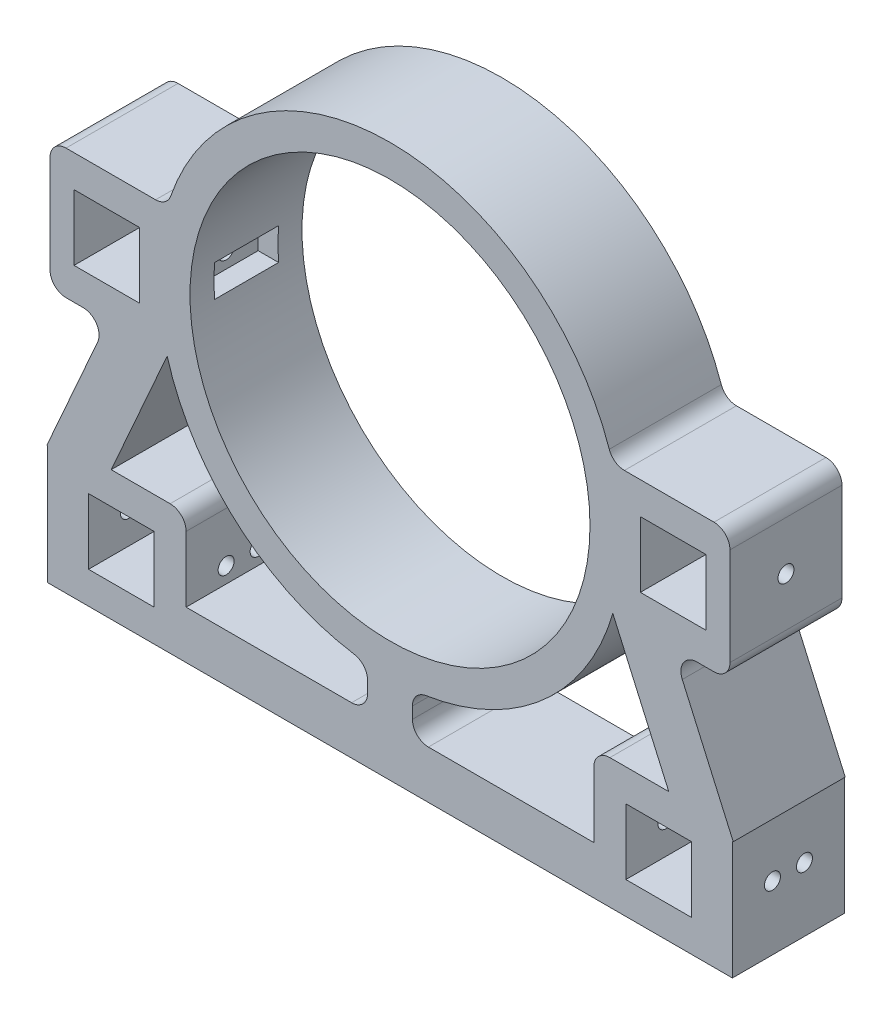
from build123d import *

# Parameters (mm, degrees)
SKETCH1_W                = 20.5
SKETCH1_H                = 20.5
SKETCH1_R                = 62.5
BOSS_EXTRUDE1_DEPTH      = 35
FILLET2_R                = 5
SKETCH2_W                = 20
SKETCH2_H                = 10
CUT_EXTRUDE2_DEPTH       = 7
SKETCH3_W                = 20
SKETCH3_H                = 10
CUT_EXTRUDE3_DEPTH       = 7
SKETCH4_W                = 35
SKETCH4_H                = 37
CUT_EXTRUDE4_DEPTH       = 10
SKETCH5_W                = 35
SKETCH5_H                = 37
CUT_EXTRUDE5_DEPTH       = 10
SKETCH6_W                = 35
SKETCH6_H                = 40.5
CUT_EXTRUDE8_DEPTH       = 2.5
SKETCH7_W                = 35
SKETCH7_H                = 40.5
CUT_EXTRUDE9_DEPTH       = 2.5
FILLET3_R                = 5
SKETCH8_R                = 2.5
CUT_EXTRUDE10_DEPTH      = 194
CUT_EXTRUDE10_DEPTH_BACK = 48
SKETCH9_R                = 2.5
CUT_EXTRUDE11_DEPTH      = 48
CUT_EXTRUDE11_DEPTH_BACK = 48
SKETCH10_R               = 2.5
CUT_EXTRUDE12_DEPTH      = 48
CUT_EXTRUDE12_DEPTH_BACK = 48


with BuildPart() as part:
    # Sketch1 → Boss-Extrude1 (new body)
    with BuildSketch(Plane.XY):
        with BuildLine():
            Line((117, -100.161277705), (117, -85.161277705))
            Line((117, -85.161277705), (88.226517383, -20.181680312))
            Line((88.226517383, -20.181680312), (108.734784021, -20.181680312))
            Line((108.734784021, -20.181680312), (108.734784021, 20.318319688))
            Line((108.734784021, 20.318319688), (69.594654141, 20.318319688))
            ThreePointArc((69.594654141, 20.318319688), (0, 72.5), (-69.594654141, 20.318319688))
            Line((-69.594654141, 20.318319688), (-108.734784021, 20.318319688))
            Line((-108.734784021, 20.318319688), (-108.734784021, -20.181680312))
            Line((-108.734784021, -20.181680312), (-88.226517383, -20.181680312))
            Line((-88.226517383, -20.181680312), (-117, -85.161277705))
            Line((-117, -85.161277705), (-117, -100.161277705))
            Line((-117, -100.161277705), (117, -100.161277705))
        make_face()
        with Locations((83.958397156, -79.911277705)):
            Rectangle(SKETCH1_W, SKETCH1_H, mode=Mode.SUBTRACT)
        with Locations((-83.958397156, -79.911277705)):
            Rectangle(SKETCH1_W, SKETCH1_H, mode=Mode.SUBTRACT)
        with BuildLine():
            Line((-63.708397156, -59.661277705), (-87.116280609, -59.661277705))
            Line((-87.116280609, -59.661277705), (-69.634400836, -20.181680312))
            ThreePointArc((-69.634400836, -20.181680312), (-46.29986484, -55.79043391), (-7, -72.161277705))
            Line((-7, -72.161277705), (-7, -85.161277705))
            Line((-7, -85.161277705), (-63.708397156, -85.161277705))
            Line((-63.708397156, -85.161277705), (-63.708397156, -59.661277705))
        make_face(mode=Mode.SUBTRACT)
        with BuildLine():
            Line((87.116280609, -59.661277705), (63.708397156, -59.661277705))
            Line((63.708397156, -59.661277705), (63.708397156, -85.161277705))
            Line((63.708397156, -85.161277705), (7, -85.161277705))
            Line((7, -85.161277705), (7, -72.161277705))
            ThreePointArc((7, -72.161277705), (46.29986484, -55.79043391), (69.634400836, -20.181680312))
            Line((69.634400836, -20.181680312), (87.116280609, -59.661277705))
        make_face(mode=Mode.SUBTRACT)
        with Locations((-88.484784021, 0.068319688)):
            Rectangle(SKETCH1_W, SKETCH1_H, mode=Mode.SUBTRACT)
        Circle(SKETCH1_R, mode=Mode.SUBTRACT)
        with Locations((88.484784021, 0.068319688)):
            Rectangle(SKETCH1_W, SKETCH1_H, mode=Mode.SUBTRACT)
    extrude(amount=BOSS_EXTRUDE1_DEPTH)

    # Fillet2
    fillet2_edges = [part.edges().sort_by_distance(p)[0] for p in [
        (-88.226517383, -20.181680312, 17.5),
        (-69.594654141, 20.318319688, 17.5),
        (69.594654141, 20.318319688, 17.5),
        (88.226517383, -20.181680312, 17.5),
        (7, -72.161277705, 17.5),
        (7, -85.161277705, 17.5),
        (63.708397156, -59.661277705, 17.5),
        (-63.708397156, -59.661277705, 17.5),
        (-7, -85.161277705, 17.5),
        (-7, -72.161277705, 17.5),
    ]]
    fillet(fillet2_edges, radius=FILLET2_R)

    # Sketch2 → Cut-Extrude2 (cut)
    with BuildSketch(Plane(origin=(61.7, 0, 0), x_dir=(0, 0, -1), z_dir=(1, 0, 0))):
        with Locations((-17.5, 0.068319688)):
            Rectangle(SKETCH2_W, SKETCH2_H)
    extrude(amount=CUT_EXTRUDE2_DEPTH, mode=Mode.SUBTRACT)

    # Sketch3 → Cut-Extrude3 (cut)
    with BuildSketch(Plane(origin=(-61.7, 0, 0), x_dir=(0, 0, -1), z_dir=(1, 0, 0))):
        with Locations((-17.5, 0.068319688)):
            Rectangle(SKETCH3_W, SKETCH3_H)
    extrude(amount=-CUT_EXTRUDE3_DEPTH, mode=Mode.SUBTRACT)

    # Sketch4 → Cut-Extrude4 (cut)
    with BuildSketch(Plane(origin=(117, 0, 0), x_dir=(0, 0, -1), z_dir=(1, 0, 0))):
        with Locations((-17.5, -81.661277705)):
            Rectangle(SKETCH4_W, SKETCH4_H)
    extrude(amount=-CUT_EXTRUDE4_DEPTH, mode=Mode.SUBTRACT)

    # Sketch5 → Cut-Extrude5 (cut)
    with BuildSketch(Plane.ZY.offset(117)):
        with Locations((17.5, -81.661277705)):
            Rectangle(SKETCH5_W, SKETCH5_H)
    extrude(amount=-CUT_EXTRUDE5_DEPTH, mode=Mode.SUBTRACT)

    # Sketch6 → Cut-Extrude8 (cut)
    with BuildSketch(Plane(origin=(108.734784021, 0, 0), x_dir=(0, 0, -1), z_dir=(1, 0, 0))):
        with Locations((-17.5, 0.068319688)):
            Rectangle(SKETCH6_W, SKETCH6_H)
    extrude(amount=-CUT_EXTRUDE8_DEPTH, mode=Mode.SUBTRACT)

    # Sketch7 → Cut-Extrude9 (cut)
    with BuildSketch(Plane.ZY.offset(108.734784021)):
        with Locations((17.5, 0.068319688)):
            Rectangle(SKETCH7_W, SKETCH7_H)
    extrude(amount=-CUT_EXTRUDE9_DEPTH, mode=Mode.SUBTRACT)

    # Fillet3
    fillet3_edges = [part.edges().sort_by_distance(p)[0] for p in [
        (106.234784021, 20.318319688, 17.5),
        (106.234784021, -20.181680312, 17.5),
        (-106.234784021, 20.318319688, 17.5),
        (-106.234784021, -20.181680312, 17.5),
    ]]
    fillet(fillet3_edges, radius=FILLET3_R)

    # Sketch8 → Cut-Extrude10 (cut, two sides)
    with BuildSketch(Plane(origin=(-68.7, 0, 0), x_dir=(0, 0, -1), z_dir=(1, 0, 0))) as cut_extrude10_sk:
        with Locations((-17.5, 0.068319688)):
            Circle(SKETCH8_R)
    extrude(amount=CUT_EXTRUDE10_DEPTH, mode=Mode.SUBTRACT)
    extrude(cut_extrude10_sk.sketch, amount=-CUT_EXTRUDE10_DEPTH_BACK, mode=Mode.SUBTRACT)

    # Sketch9 → Cut-Extrude11 (cut, two sides)
    with BuildSketch(Plane(origin=(-94.208397156, 0, 0), x_dir=(0, 0, -1), z_dir=(1, 0, 0))) as cut_extrude11_sk:
        with Locations((-22.5, -80.161277705)):
            Circle(SKETCH9_R)
        with Locations((-12.5, -80.161277705)):
            Circle(SKETCH9_R)
    extrude(amount=CUT_EXTRUDE11_DEPTH, mode=Mode.SUBTRACT)
    extrude(cut_extrude11_sk.sketch, amount=-CUT_EXTRUDE11_DEPTH_BACK, mode=Mode.SUBTRACT)

    # Sketch10 → Cut-Extrude12 (cut, two sides)
    with BuildSketch(Plane.ZY.offset(-94.208397156)) as cut_extrude12_sk:
        with Locations((12.5, -80.161277705)):
            Circle(SKETCH10_R)
        with Locations((22.5, -80.161277705)):
            Circle(SKETCH10_R)
    extrude(amount=CUT_EXTRUDE12_DEPTH, mode=Mode.SUBTRACT)
    extrude(cut_extrude12_sk.sketch, amount=-CUT_EXTRUDE12_DEPTH_BACK, mode=Mode.SUBTRACT)


solid = part.part
